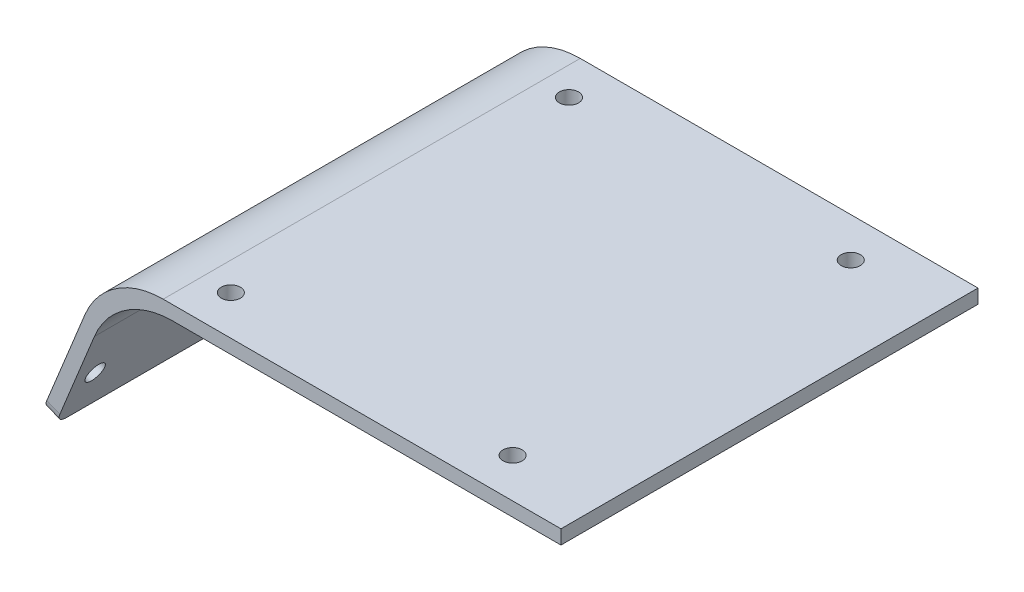
from build123d import *

# Parameters (mm, degrees)
ESTRUSIONE_ESTRUSIONE2_DEPTH  = 74
RACCORDO3_R                   = 15
RACCORDO4_R                   = 2
SCHIZZO10_R                   = 1.7
TAGLIO_ESTRUSIONE1_DEPTH      = 10
SCHIZZO13_R                   = 1.7
TAGLIO_ESTRUSIONE3_DEPTH      = 11.491186204
TAGLIO_ESTRUSIONE3_DEPTH_BACK = 86.53385939


with BuildPart() as part:
    # Schizzo2 → Estrusione-Estrusione2 (new body)
    with BuildSketch(Plane.XY):
        Polygon((-60, 40.884860172), (20.66, 40.884860172), (20.66, 38.384860172), (-58.319751134, 38.384860172), (-69.015504429, 12.162557341), (-71.330346702, 13.1067529), align=None)
    extrude(amount=ESTRUSIONE_ESTRUSIONE2_DEPTH)

    # Raccordo3
    raccordo3_edges = [part.edges().sort_by_distance(p)[0] for p in [
        (-60, 40.884860172, 37),
        (-58.319751134, 38.384860172, 37),
    ]]
    fillet(raccordo3_edges, radius=RACCORDO3_R)

    # Raccordo4
    raccordo4_edges = [part.edges().sort_by_distance(p)[0] for p in [
        (-70.172925565, 12.63465512, 74),
        (-70.172925565, 12.63465512, 0),
    ]]
    fillet(raccordo4_edges, radius=RACCORDO4_R)

    # Schizzo10 → Taglio-Estrusione1 (cut)
    with BuildSketch(Plane(origin=(0, 40.884860172, 0), x_dir=(1, 0, 0), z_dir=(0, 1, 0))):
        with Locations((5.081493197, -67)):
            Circle(SCHIZZO10_R)
        with Locations((5.081493197, -7)):
            Circle(SCHIZZO10_R)
        with Locations((-44.918506803, -67)):
            Circle(SCHIZZO10_R)
        with Locations((-44.918506803, -7)):
            Circle(SCHIZZO10_R)
    extrude(amount=-TAGLIO_ESTRUSIONE1_DEPTH, mode=Mode.SUBTRACT)

    # Schizzo13 → Taglio-Estrusione3 (cut, two sides)
    with BuildSketch(Plane(origin=(-65.73923894, 26.814223222, 0), x_dir=(0, 0, 1), z_dir=(-0.925936909, 0.377678223, 0))) as taglio_estrusione3_sk:
        with Locations((4, -6.803892348)):
            Circle(SCHIZZO13_R)
        with Locations((70, -6.803892348)):
            Circle(SCHIZZO13_R)
        with Locations((35, -6.803892348)):
            Circle(SCHIZZO13_R)
    extrude(amount=TAGLIO_ESTRUSIONE3_DEPTH, mode=Mode.SUBTRACT)
    extrude(taglio_estrusione3_sk.sketch, amount=-TAGLIO_ESTRUSIONE3_DEPTH_BACK, mode=Mode.SUBTRACT)


solid = part.part
